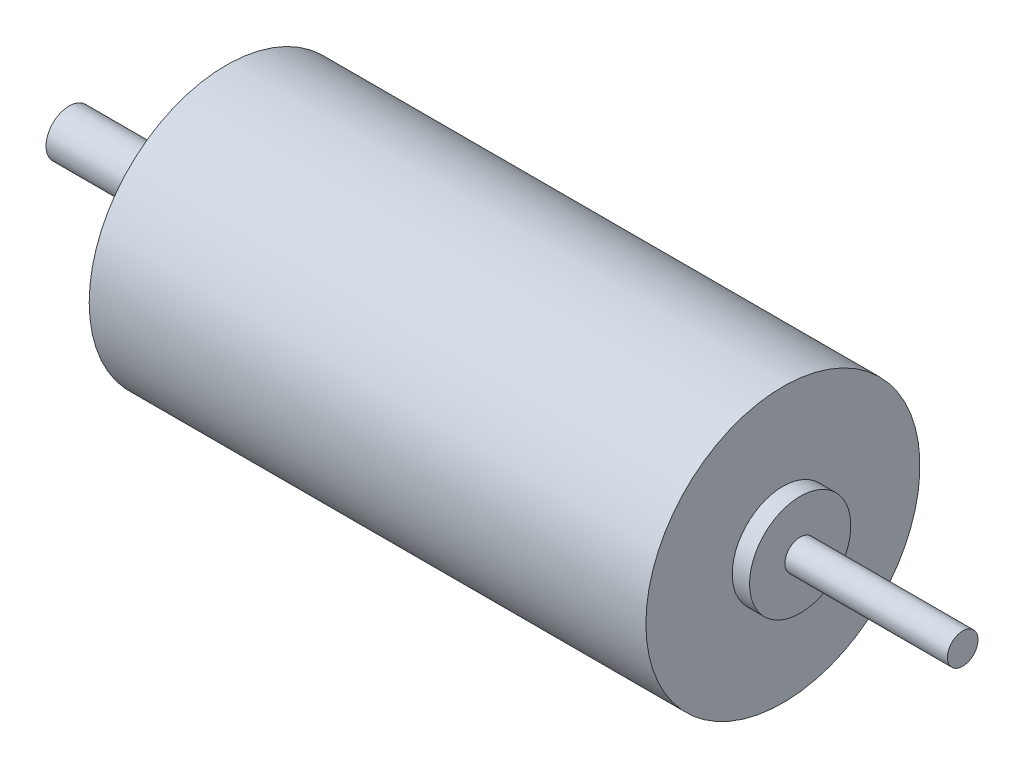
from build123d import *


with BuildPart() as part:
    # Sketch1 → Revolve1 (revolve)
    with BuildSketch(Plane.XY):
        Polygon((-106.458572994, 10.313003027), (-106.458572994, 13.263003027), (-88.658572994, 13.263003027), (-88.658572994, 16.763003027), (-86.458572994, 16.763003027), (-86.458572994, 27.763003027), (-15.558572994, 27.763003027), (-15.558572994, 16.763003027), (-13.358572994, 16.763003027), (-13.358572994, 12.263003027), (7.341427006, 12.263003027), (7.341427006, 10.313003027), align=None)
    revolve(axis=Axis((-106.458572994, 10.313003027, 0), (1, 0, 0)))


solid = part.part
